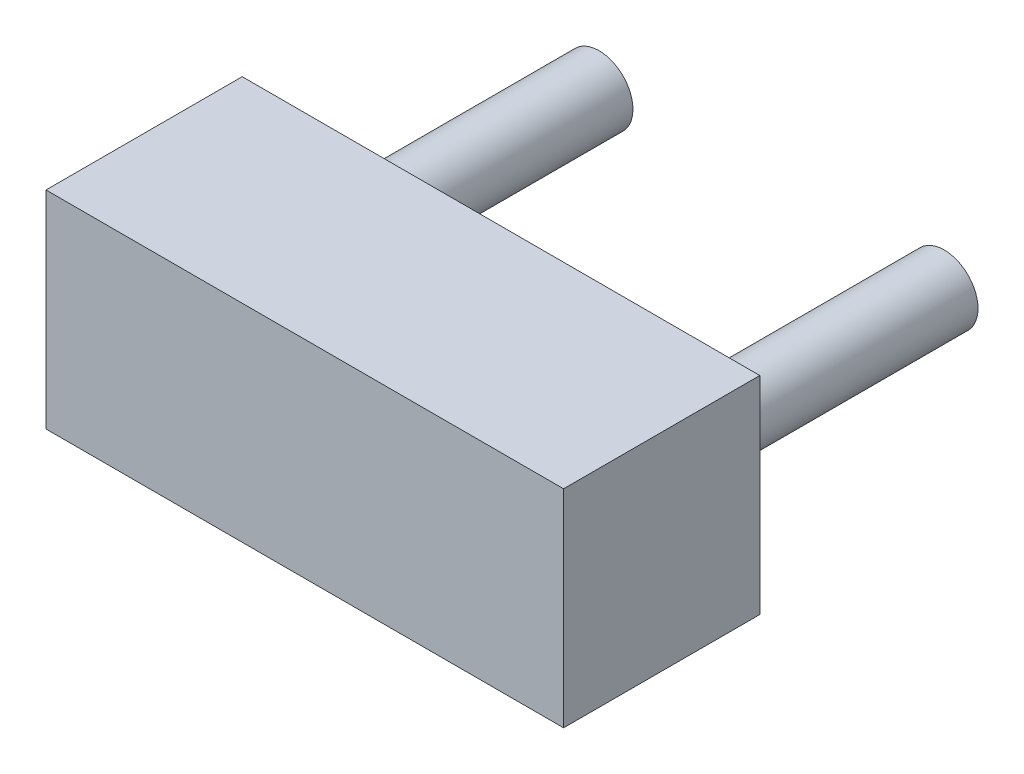
from build123d import *

# Parameters (mm, degrees)
SKETCH1_W               = 3.825
SKETCH1_H               = 1.53
COMPONENT_OUTLINE_DEPTH = 1.45
SKETCH2_R               = 0.25
EXTRUDE_1_DEPTH         = 2
SKETCH3_R               = 0.25
EXTRUDE_2_DEPTH         = 2


with BuildPart() as part:
    # Sketch1 → Component_Outline (new body)
    with BuildSketch(Plane.XY):
        Rectangle(SKETCH1_W, SKETCH1_H)
    extrude(amount=COMPONENT_OUTLINE_DEPTH)


with BuildPart() as body_2:
    # Sketch2 → Extrude 1 (new body)
    with BuildSketch(Plane.XY):
        with Locations((-1.275, 0)):
            Circle(SKETCH2_R)
    extrude(amount=-EXTRUDE_1_DEPTH)


with BuildPart() as body_3:
    # Sketch3 → Extrude 2 (new body)
    with BuildSketch(Plane.XY):
        with Locations((1.275, 0)):
            Circle(SKETCH3_R)
    extrude(amount=-EXTRUDE_2_DEPTH)


solid = Compound([part.part, body_2.part, body_3.part])
